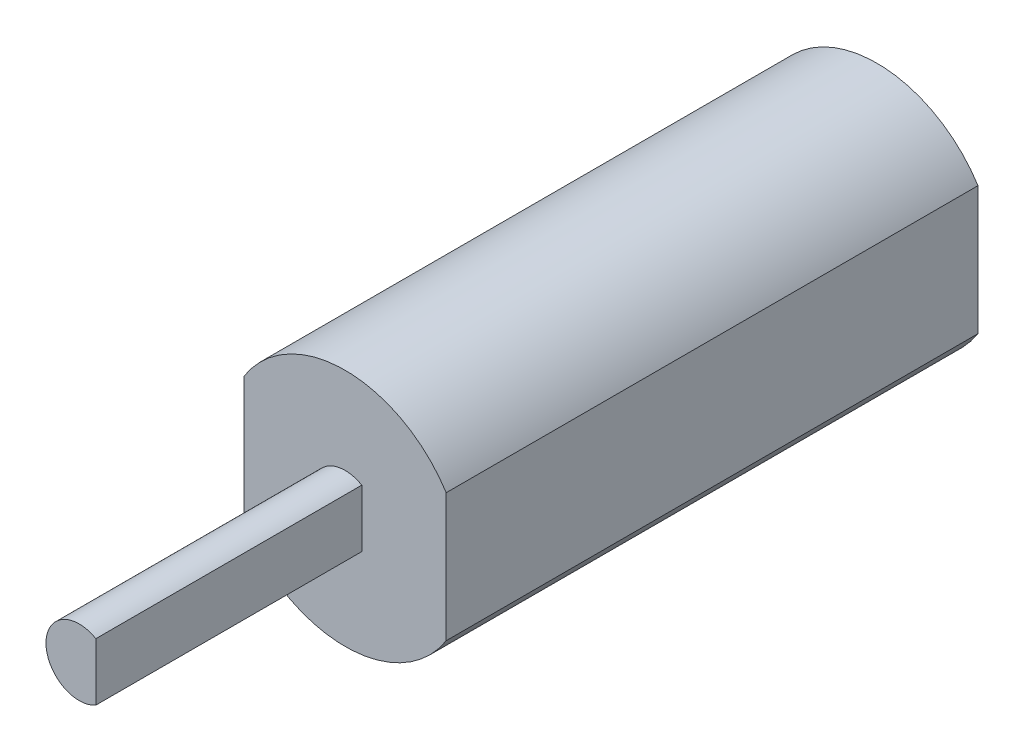
from build123d import *

# Parameters (mm, degrees)
BOSS_EXTRUDE1_DEPTH = 25.4
BOSS_EXTRUDE2_DEPTH = 12.7


with BuildPart() as part:
    # Sketch1 → Boss-Extrude1 (new body)
    with BuildSketch(Plane.XY):
        with BuildLine():
            Line((-4.826, 0.016704998), (-4.826, -3.044495583))
            ThreePointArc((-4.826, -3.044495583), (0, -5.698295002), (4.826, -3.044495583))
            Line((4.826, -3.044495583), (4.826, 0.016704998))
            Line((4.826, 0.016704998), (4.826, 3.07790558))
            ThreePointArc((4.826, 3.07790558), (0, 5.731704998), (-4.826, 3.07790558))
            Line((-4.826, 3.07790558), (-4.826, 0.016704998))
        make_face()
    extrude(amount=BOSS_EXTRUDE1_DEPTH)

    # Sketch2 → Boss-Extrude2 (add)
    with BuildSketch(Plane.XY.offset(25.4)):
        with BuildLine():
            Line((0.79375, 0), (0.79375, 1.374815329))
            ThreePointArc((0.79375, 1.374815329), (-1.5875, 0), (0.79375, -1.374815329))
            Line((0.79375, -1.374815329), (0.79375, 0))
        make_face()
    extrude(amount=BOSS_EXTRUDE2_DEPTH)


solid = part.part
